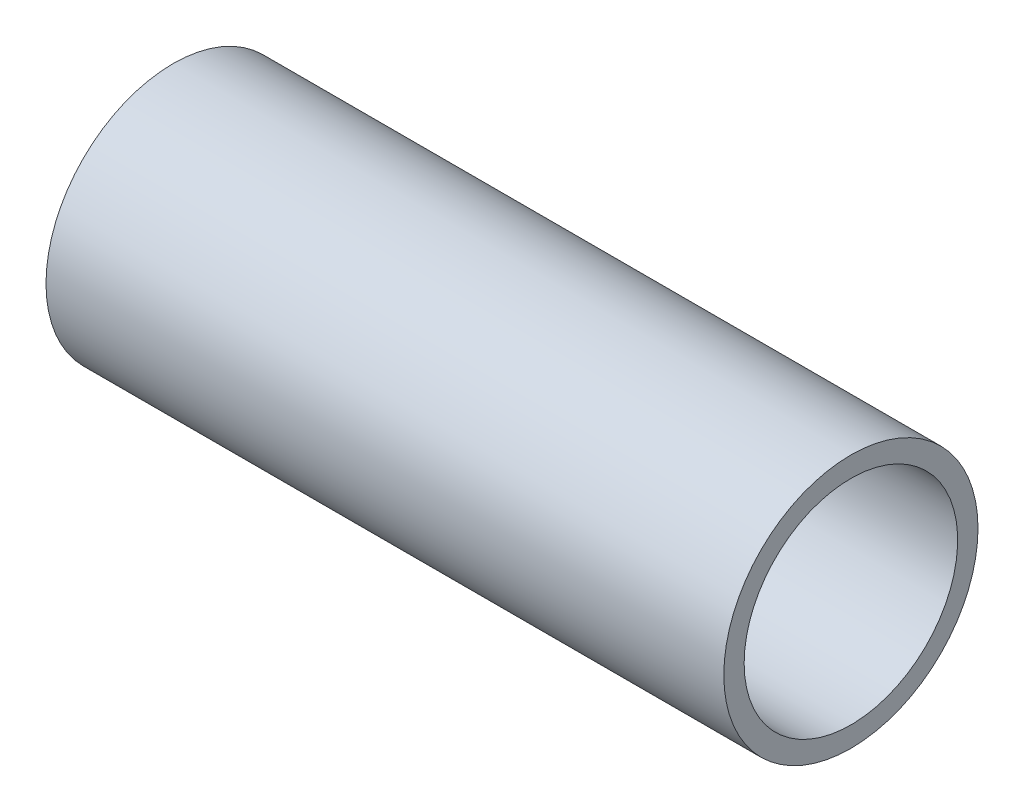
from build123d import *

# Parameters (mm, degrees)
SKETCH1_R           = 9.525
BOSS_EXTRUDE1_DEPTH = 50.8
SKETCH3_R           = 8.509
CUT_EXTRUDE1_DEPTH  = 1.524
SKETCH4_R           = 8.001
CUT_EXTRUDE2_DEPTH  = 50.276


with BuildPart() as part:
    # Sketch1 → Boss-Extrude1 (new body)
    with BuildSketch(Plane(origin=(0, 0, 0), x_dir=(0, 0, -1), z_dir=(1, 0, 0))):
        Circle(SKETCH1_R)
    extrude(amount=BOSS_EXTRUDE1_DEPTH)

    # Sketch3 → Cut-Extrude1 (cut)
    with BuildSketch(Plane.ZY):
        Circle(SKETCH3_R)
    extrude(amount=-CUT_EXTRUDE1_DEPTH, mode=Mode.SUBTRACT)

    # Sketch4 → Cut-Extrude2 (cut, through all)
    with BuildSketch(Plane.ZY.offset(-1.524)):
        Circle(SKETCH4_R)
    extrude(amount=-CUT_EXTRUDE2_DEPTH, mode=Mode.SUBTRACT)


solid = part.part
